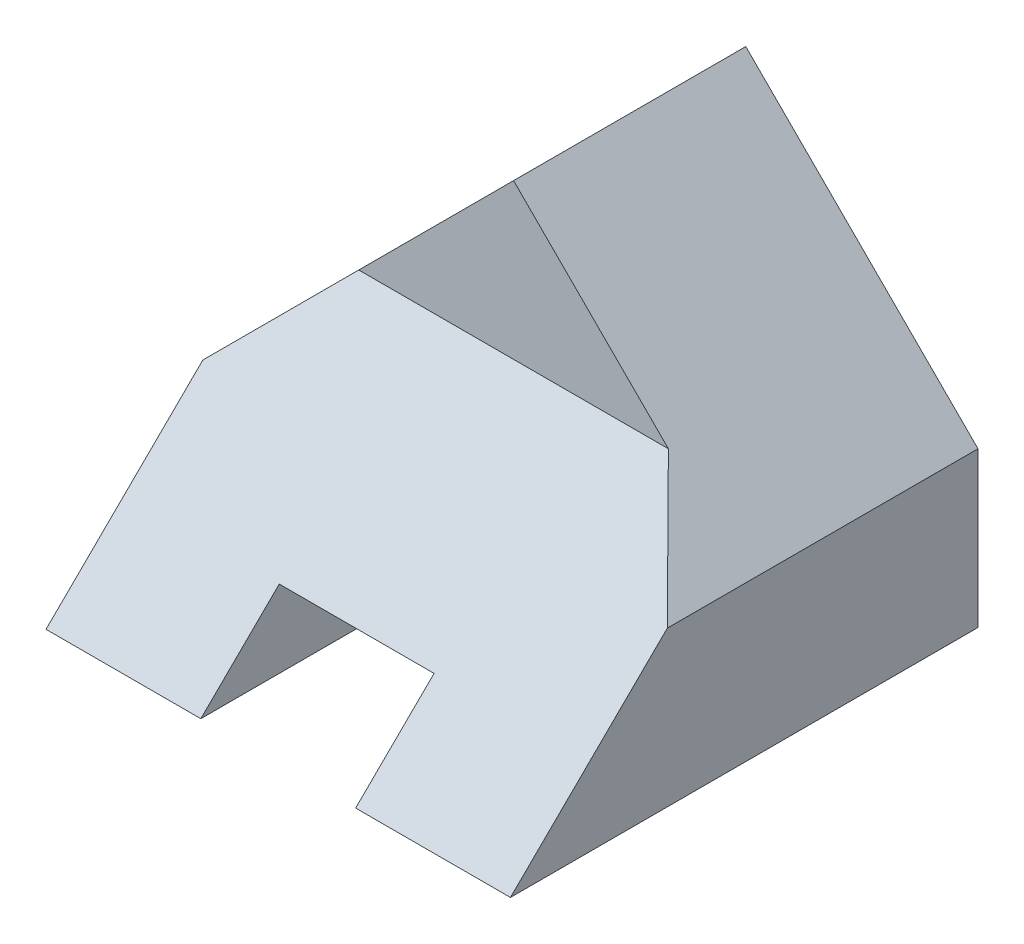
from build123d import *

# Parameters (mm, degrees)
BOSS_EXTRUDE1_DEPTH = 3
BOSS_EXTRUDE2_DEPTH = 6
SKETCH3_W           = 2
SKETCH3_H           = 1
CUT_EXTRUDE1_DEPTH  = 6


with BuildPart() as part:
    # Sketch1 → Boss-Extrude1 (new body)
    with BuildSketch(Plane.XY):
        Polygon((3, 0), (-3, 0), (-3, 2), (0, 5), (3, 2), align=None)
    extrude(amount=-BOSS_EXTRUDE1_DEPTH)

    # Sketch2 → Boss-Extrude2 (add)
    with BuildSketch(Plane(origin=(3, 0, 0), x_dir=(0, 0, -1), z_dir=(1, 0, 0))):
        Polygon((0, 3), (-3.04018422, 0), (0, 0), align=None)
    extrude(amount=-BOSS_EXTRUDE2_DEPTH)

    # Sketch3 → Cut-Extrude1 (cut)
    with BuildSketch(Plane.XY):
        Polygon((-2, 3), (-3, 2), (-3, 3), align=None)
        Polygon((2, 3), (3, 2), (3, 3), align=None)
        with Locations((0, 0.5)):
            Rectangle(SKETCH3_W, SKETCH3_H)
    extrude(amount=CUT_EXTRUDE1_DEPTH, mode=Mode.SUBTRACT)


solid = part.part
